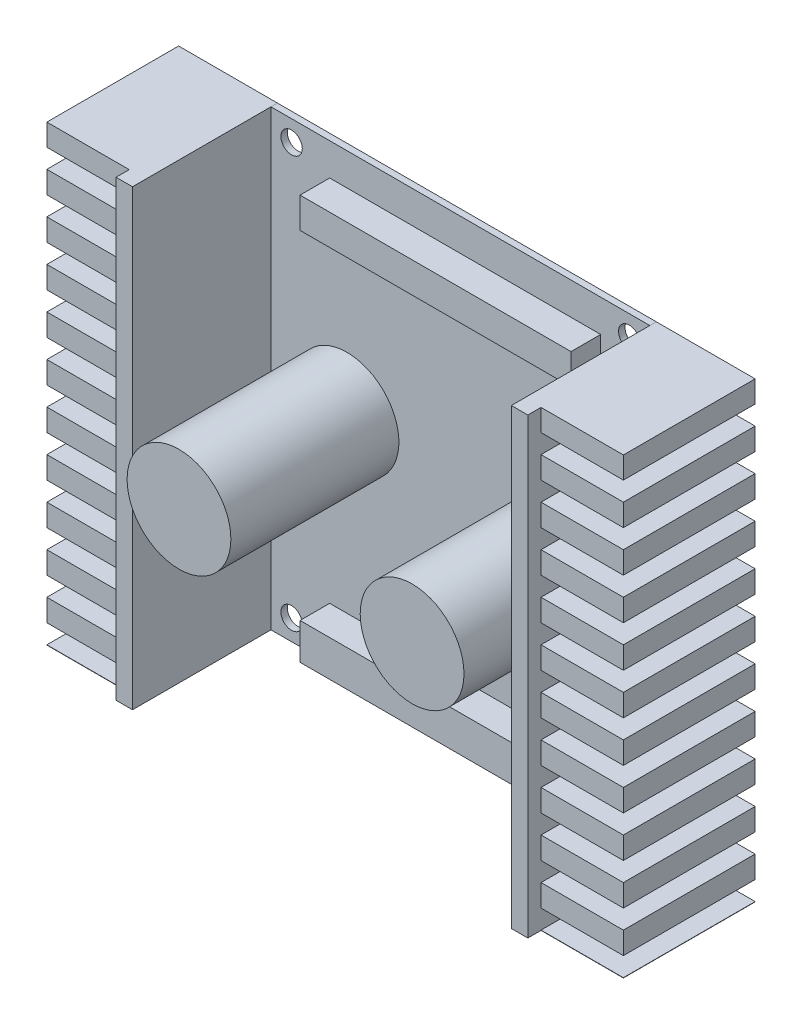
from build123d import *

# Parameters (mm, degrees)
SKETCH1_W             = 58.42
SKETCH1_H             = 69.85
SKETCH1_R             = 1.651
BOSS_EXTRUDE1_DEPTH   = 1
SKETCH2_W             = 2.54
SKETCH2_H             = 69.85
BOSS_EXTRUDE2_DEPTH   = 22.352
BOSS_EXTRUDE2_2_DEPTH = 22.352
SKETCH2_3_W           = 12.7
SKETCH2_3_H           = 69.85
BOSS_EXTRUDE3_DEPTH   = 20.32
SKETCH3_W             = 12.7
SKETCH3_H             = 2.942970032
CUT_EXTRUDE3_DEPTH    = 37.084
SKETCH4_R             = 8.001
BOSS_EXTRUDE4_DEPTH   = 25.908
SKETCH5_W             = 41.790174447
SKETCH5_H             = 4.70875205
SKETCH5_H_2           = 5.59164306
BOSS_EXTRUDE5_DEPTH   = 4.572


with BuildPart() as part:
    # Sketch1 → Boss-Extrude1 (new body)
    with BuildSketch(Plane.XY):
        Rectangle(SKETCH1_W, SKETCH1_H)
        with Locations((-26.035, 31.75)):
            Circle(SKETCH1_R, mode=Mode.SUBTRACT)
        with Locations((-26.035, -31.75)):
            Circle(SKETCH1_R, mode=Mode.SUBTRACT)
        with Locations((26.035, -31.75)):
            Circle(SKETCH1_R, mode=Mode.SUBTRACT)
        with Locations((26.035, 31.75)):
            Circle(SKETCH1_R, mode=Mode.SUBTRACT)
    extrude(amount=BOSS_EXTRUDE1_DEPTH)

    # Sketch4 → Boss-Extrude4 (add)
    with BuildSketch(Plane.XY.offset(1)):
        with Locations((-17.486501, 0)):
            Circle(SKETCH4_R)
        with Locations((18.457973277, 0)):
            Circle(SKETCH4_R)
    extrude(amount=BOSS_EXTRUDE4_DEPTH)

    # Sketch5 → Boss-Extrude5 (add)
    with BuildSketch(Plane.XY.offset(1)):
        with Locations((0.735742508, 27.590344045)):
            Rectangle(SKETCH5_W, SKETCH5_H)
        with Locations((0.735742508, -29.650423067)):
            Rectangle(SKETCH5_W, SKETCH5_H_2)
    extrude(amount=BOSS_EXTRUDE5_DEPTH)


with BuildPart() as body_2:
    # Sketch2 → Boss-Extrude2 (new body)
    with BuildSketch(Plane(origin=(0, 0, 0), x_dir=(-1, 0, 0), z_dir=(0, 0, -1))):
        with Locations((30.48, 0)):
            Rectangle(SKETCH2_W, SKETCH2_H)
    extrude(amount=-BOSS_EXTRUDE2_DEPTH)



with BuildPart() as body_3:
    # Sketch2 → Boss-Extrude2 2 (new body)
    with BuildSketch(Plane(origin=(0, 0, 0), x_dir=(-1, 0, 0), z_dir=(0, 0, -1))):
        with Locations((-30.48, 0)):
            Rectangle(SKETCH2_W, SKETCH2_H)
    extrude(amount=-BOSS_EXTRUDE2_2_DEPTH)


with BuildPart() as body_2_1:
    add(body_2.part)

    add(body_3.part)  # Boss-Extrude3 merges body 3
    # Sketch2_3 → Boss-Extrude3 (add)
    with BuildSketch(Plane(origin=(0, 0, 0), x_dir=(-1, 0, 0), z_dir=(0, 0, -1))):
        with Locations((38.1, 0)):
            Rectangle(SKETCH2_3_W, SKETCH2_3_H)
        with Locations((-38.1, 0)):
            Rectangle(SKETCH2_3_W, SKETCH2_3_H)
    extrude(amount=-BOSS_EXTRUDE3_DEPTH)

    # Sketch3 → Cut-Extrude3 (cut)
    with BuildSketch(Plane.XY.offset(22.352)):
        with Locations((-38.1, 30.091868572)):
            Rectangle(SKETCH3_W, SKETCH3_H)
        with Locations((-38.1, 23.741868572)):
            Rectangle(SKETCH3_W, SKETCH3_H)
        with Locations((-38.1, 17.391868572)):
            Rectangle(SKETCH3_W, SKETCH3_H)
        with Locations((-38.1, 11.041868572)):
            Rectangle(SKETCH3_W, SKETCH3_H)
        with Locations((-38.1, 4.691868572)):
            Rectangle(SKETCH3_W, SKETCH3_H)
        with Locations((-38.1, -1.658131428)):
            Rectangle(SKETCH3_W, SKETCH3_H)
        with Locations((-38.1, -8.008131428)):
            Rectangle(SKETCH3_W, SKETCH3_H)
        with Locations((-38.1, -14.358131428)):
            Rectangle(SKETCH3_W, SKETCH3_H)
        with Locations((-38.1, -20.708131428)):
            Rectangle(SKETCH3_W, SKETCH3_H)
        with Locations((-38.1, -27.058131428)):
            Rectangle(SKETCH3_W, SKETCH3_H)
        with Locations((-38.1, -33.408131428)):
            Rectangle(SKETCH3_W, SKETCH3_H)
        with Locations((38.1, -33.408131428)):
            Rectangle(SKETCH3_W, SKETCH3_H)
        with Locations((38.1, -27.058131428)):
            Rectangle(SKETCH3_W, SKETCH3_H)
        with Locations((38.1, -20.708131428)):
            Rectangle(SKETCH3_W, SKETCH3_H)
        with Locations((38.1, -14.358131428)):
            Rectangle(SKETCH3_W, SKETCH3_H)
        with Locations((38.1, -8.008131428)):
            Rectangle(SKETCH3_W, SKETCH3_H)
        with Locations((38.1, -1.658131428)):
            Rectangle(SKETCH3_W, SKETCH3_H)
        with Locations((38.1, 4.691868572)):
            Rectangle(SKETCH3_W, SKETCH3_H)
        with Locations((38.1, 11.041868572)):
            Rectangle(SKETCH3_W, SKETCH3_H)
        with Locations((38.1, 17.391868572)):
            Rectangle(SKETCH3_W, SKETCH3_H)
        with Locations((38.1, 23.741868572)):
            Rectangle(SKETCH3_W, SKETCH3_H)
        with Locations((38.1, 30.091868572)):
            Rectangle(SKETCH3_W, SKETCH3_H)
    extrude(amount=-CUT_EXTRUDE3_DEPTH, mode=Mode.SUBTRACT)


solid = Compound([part.part, body_2_1.part])
